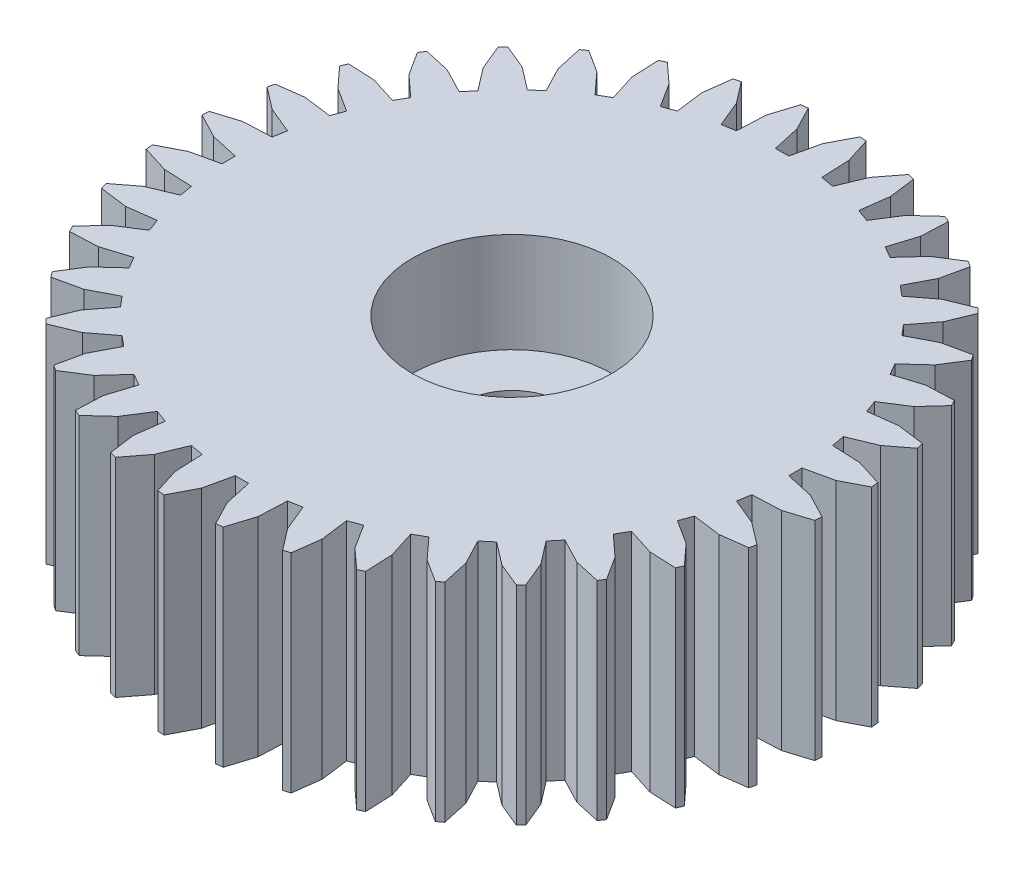
from build123d import *

# Parameters (mm, degrees)
SKETCH1_R           = 10.0584
BOSS_EXTRUDE1_DEPTH = 6.35
SKETCH2_R           = 1.524
CUT_EXTRUDE1_DEPTH  = 7.35
SKETCH3_R           = 3.048
CUT_EXTRUDE2_DEPTH  = 3.048
CUT_EXTRUDE3_DEPTH  = 7.35
CIRPATTERN1_COUNT   = 36


with BuildPart() as part:
    # Sketch1 → Boss-Extrude1 (new body)
    with BuildSketch(Plane(origin=(0, 0, 0), x_dir=(1, 0, 0), z_dir=(0, 1, 0))):
        Circle(SKETCH1_R)
    extrude(amount=BOSS_EXTRUDE1_DEPTH)

    # Sketch2 → Cut-Extrude1 (cut, through all)
    with BuildSketch(Plane(origin=(0, 6.35, 0), x_dir=(1, 0, 0), z_dir=(0, 1, 0))):
        Circle(SKETCH2_R)
    extrude(amount=-CUT_EXTRUDE1_DEPTH, mode=Mode.SUBTRACT)

    # Sketch3 → Cut-Extrude2 (cut)
    with BuildSketch(Plane(origin=(0, 6.35, 0), x_dir=(1, 0, 0), z_dir=(0, 1, 0))):
        Circle(SKETCH3_R)
    extrude(amount=-CUT_EXTRUDE2_DEPTH, mode=Mode.SUBTRACT)

    # Sketch4 → Cut-Extrude3 (cut, through all)
    with BuildSketch(Plane.XZ):
        Polygon((-26.806716732, -59.6465888), (-0.992739546, -10.0584), (-0.593526671, -9.291519201), (-0.4064, -8.447445337), (0, -8.447445337), (0.187126671, -9.291519201), (0.586339546, -10.0584), (26.400316732, -59.6465888), (26.400316732, -171.456246463), (-26.806716732, -171.456246463), align=None)
    cut_extrude3 = extrude(amount=-CUT_EXTRUDE3_DEPTH, mode=Mode.SUBTRACT)

    # CirPattern1: Cut-Extrude3 ×36 about axis
    cirpattern1_axis = Axis((0, 0, 0), (0, 1, 0))
    for i in range(1, CIRPATTERN1_COUNT):
        add(cut_extrude3.rotate(cirpattern1_axis, i * 360 / CIRPATTERN1_COUNT), mode=Mode.SUBTRACT)


solid = part.part
